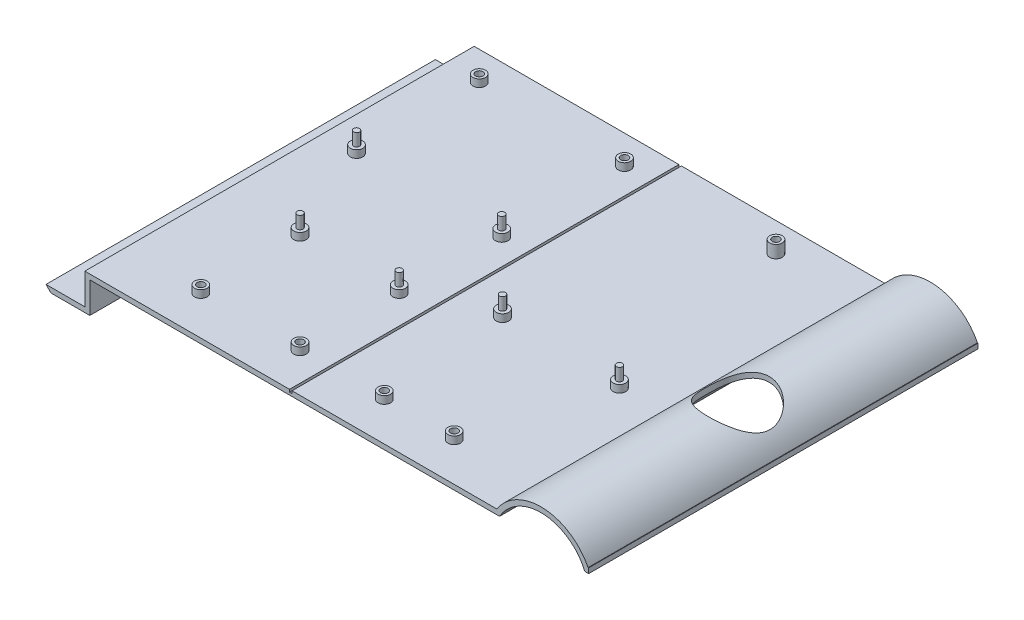
from build123d import *

# Parameters (mm, degrees)
LINEAR_AUSTRAGEN_D_NN1_DEPTH     = 155.5
SKIZZE7_R                        = 2.5
AUFSATZ_LINEAR_AUSTRAGEN3_DEPTH  = 5
SKIZZE8_R                        = 1.5
SCHNITT_LINEAR_AUSTRAGEN1_DEPTH  = 8
SKIZZE12_R                       = 1.5
SCHNITT_LINEAR_AUSTRAGEN4_DEPTH  = 8
SKIZZE13_R                       = 2.5
AUFSATZ_LINEAR_AUSTRAGEN5_DEPTH  = 5
SKIZZE16_R                       = 1.5
SCHNITT_LINEAR_AUSTRAGEN9_DEPTH  = 8
SKIZZE17_R                       = 1.5
SCHNITT_LINEAR_AUSTRAGEN10_DEPTH = 8
SKIZZE18_R                       = 2.5
AUFSATZ_LINEAR_AUSTRAGEN6_DEPTH  = 5
SKIZZE21_R                       = 1.5
SCHNITT_LINEAR_AUSTRAGEN13_DEPTH = 8
SKIZZE22_R                       = 1.5
SCHNITT_LINEAR_AUSTRAGEN14_DEPTH = 8
SKIZZE20_R                       = 1.2
AUFSATZ_LINEAR_AUSTRAGEN7_DEPTH  = 5
SKIZZE19_R                       = 1.2
AUFSATZ_LINEAR_AUSTRAGEN8_DEPTH  = 5
SKIZZE15_R                       = 1.2
AUFSATZ_LINEAR_AUSTRAGEN9_DEPTH  = 5
SKIZZE14_R                       = 1.2
AUFSATZ_LINEAR_AUSTRAGEN11_DEPTH = 5
SKIZZE10_R                       = 1.2
AUFSATZ_LINEAR_AUSTRAGEN12_DEPTH = 5
SKIZZE11_R                       = 1.2
AUFSATZ_LINEAR_AUSTRAGEN13_DEPTH = 5
CUT_EXTRUDE2_DEPTH               = 156.5
SKIZZE23_R                       = 13
SCHNITT_LINEAR_AUSTRAGEN15_DEPTH = 13
SKETCH5_W                        = 1
SKETCH5_H                        = 155.5
CUT_EXTRUDE_THIN1_DEPTH          = 1
SKETCH6_R                        = 2.5
SKETCH6_R_2                      = 1.5
BOSS_EXTRUDE1_DEPTH              = 5
CUT_EXTRUDE3_START               = -2
SKETCH7_R                        = 1.5
CUT_EXTRUDE3_DEPTH               = 2


with BuildPart() as part:
    # Skizze5 → Linear-Austragen-Dünn1 (new body)
    with BuildSketch(Plane.XY):
        with BuildLine():
            Line((-17.5, -12.340428851), (0, -12.340428851))
            Line((0, -12.340428851), (0, 0))
            Line((0, 0), (158.213118455, 0))
            Line((158.213118455, 0), (163.626964647, 0))
            ThreePointArc((163.626964647, 0), (171.029319744, 7.247508118), (181.129906705, 9.549545901))
            ThreePointArc((181.129906705, 9.549545901), (191.077251396, 6.131307404), (197.694328428, -2.044774322))
            Line((197.694328428, -2.044774322), (199.194328428, -2.044774322))
            Line((199.194328428, -2.044774322), (199.194328428, -0.044774322))
            Line((199.194328428, -0.044774322), (198.972575208, -0.044774322))
            ThreePointArc((198.972575208, -0.044774322), (191.667573532, 8.146277022), (181.232439294, 11.546915938))
            ThreePointArc((181.232439294, 11.546915938), (170.592452046, 9.278075868), (162.50625544, 2))
            Line((162.50625544, 2), (158.213118455, 2))
            Line((158.213118455, 2), (-2, 2))
            Line((-2, 2), (-2, -10.340428851))
            Line((-2, -10.340428851), (-17.5, -10.340428851))
            Line((-17.5, -10.340428851), (-17.5, -12.340428851))
        make_face()
    extrude(amount=LINEAR_AUSTRAGEN_D_NN1_DEPTH)

    # Skizze7 → Aufsatz-Linear austragen3 (add)
    with BuildSketch(Plane(origin=(0.013003032, 0, 0), x_dir=(1, 0, 0), z_dir=(0, 1, 0))):
        with Locations((11.5, -11.5)):
            Circle(SKIZZE7_R)
        with Locations((69.5, -11.5)):
            Circle(SKIZZE7_R)
        with Locations((11.5, -60.5)):
            Circle(SKIZZE7_R)
        with Locations((69.5, -60.5)):
            Circle(SKIZZE7_R)
    extrude(amount=AUFSATZ_LINEAR_AUSTRAGEN3_DEPTH)

    # Skizze8 → Schnitt-Linear austragen1 (cut)
    with BuildSketch(Plane(origin=(0, 5, 0), x_dir=(1, 0, 0), z_dir=(0, 1, 0))):
        with Locations((11.513003032, -11.5)):
            Circle(SKIZZE8_R)
    extrude(amount=-SCHNITT_LINEAR_AUSTRAGEN1_DEPTH, mode=Mode.SUBTRACT)

    # Skizze12 → Schnitt-Linear austragen4 (cut)
    with BuildSketch(Plane(origin=(0, 5, 0), x_dir=(1, 0, 0), z_dir=(0, 1, 0))):
        with Locations((69.513003032, -11.5)):
            Circle(SKIZZE12_R)
    extrude(amount=-SCHNITT_LINEAR_AUSTRAGEN4_DEPTH, mode=Mode.SUBTRACT)

    # Skizze13 → Aufsatz-Linear austragen5 (add)
    with BuildSketch(Plane(origin=(0.013003032, 0, 0), x_dir=(1, 0, 0), z_dir=(0, 1, 0))):
        with Locations((130, -140)):
            Circle(SKIZZE13_R)
        with Locations((102.1, -140)):
            Circle(SKIZZE13_R)
        with Locations((145.2, -89.2)):
            Circle(SKIZZE13_R)
        with Locations((97.4, -88.1)):
            Circle(SKIZZE13_R)
    extrude(amount=AUFSATZ_LINEAR_AUSTRAGEN5_DEPTH)

    # Skizze16 → Schnitt-Linear austragen9 (cut)
    with BuildSketch(Plane(origin=(0, 5, 0), x_dir=(1, 0, 0), z_dir=(0, 1, 0))):
        with Locations((102.113003032, -140)):
            Circle(SKIZZE16_R)
    extrude(amount=-SCHNITT_LINEAR_AUSTRAGEN9_DEPTH, mode=Mode.SUBTRACT)

    # Skizze17 → Schnitt-Linear austragen10 (cut)
    with BuildSketch(Plane(origin=(0, 5, 0), x_dir=(1, 0, 0), z_dir=(0, 1, 0))):
        with Locations((130.013003032, -140)):
            Circle(SKIZZE17_R)
    extrude(amount=-SCHNITT_LINEAR_AUSTRAGEN10_DEPTH, mode=Mode.SUBTRACT)

    # Skizze18 → Aufsatz-Linear austragen6 (add)
    with BuildSketch(Plane(origin=(0.013003032, 0, 0), x_dir=(1, 0, 0), z_dir=(0, 1, 0))):
        with Locations((68.430981836, -140)):
            Circle(SKIZZE18_R)
        with Locations((28.830981836, -140)):
            Circle(SKIZZE18_R)
        with Locations((28.83098184, -100.4)):
            Circle(SKIZZE18_R)
        with Locations((68.430981836, -100.4)):
            Circle(SKIZZE18_R)
    extrude(amount=AUFSATZ_LINEAR_AUSTRAGEN6_DEPTH)

    # Skizze21 → Schnitt-Linear austragen13 (cut)
    with BuildSketch(Plane(origin=(0, 5, 0), x_dir=(1, 0, 0), z_dir=(0, 1, 0))):
        with Locations((28.843984868, -140)):
            Circle(SKIZZE21_R)
    extrude(amount=-SCHNITT_LINEAR_AUSTRAGEN13_DEPTH, mode=Mode.SUBTRACT)

    # Skizze22 → Schnitt-Linear austragen14 (cut)
    with BuildSketch(Plane(origin=(0, 5, 0), x_dir=(1, 0, 0), z_dir=(0, 1, 0))):
        with Locations((68.443984868, -140)):
            Circle(SKIZZE22_R)
    extrude(amount=-SCHNITT_LINEAR_AUSTRAGEN14_DEPTH, mode=Mode.SUBTRACT)

    # Skizze20 → Aufsatz-Linear austragen7 (add)
    with BuildSketch(Plane(origin=(0, 5, 0), x_dir=(1, 0, 0), z_dir=(0, 1, 0))):
        with Locations((28.843984872, -100.4)):
            Circle(SKIZZE20_R)
    extrude(amount=AUFSATZ_LINEAR_AUSTRAGEN7_DEPTH)

    # Skizze19 → Aufsatz-Linear austragen8 (add)
    with BuildSketch(Plane(origin=(0, 5, 0), x_dir=(1, 0, 0), z_dir=(0, 1, 0))):
        with Locations((68.443984868, -100.4)):
            Circle(SKIZZE19_R)
    extrude(amount=AUFSATZ_LINEAR_AUSTRAGEN8_DEPTH)

    # Skizze15 → Aufsatz-Linear austragen9 (add)
    with BuildSketch(Plane(origin=(0, 5, 0), x_dir=(1, 0, 0), z_dir=(0, 1, 0))):
        with Locations((97.413003032, -88.1)):
            Circle(SKIZZE15_R)
    extrude(amount=AUFSATZ_LINEAR_AUSTRAGEN9_DEPTH)

    # Skizze14 → Aufsatz-Linear austragen11 (add)
    with BuildSketch(Plane(origin=(0, 5, 0), x_dir=(1, 0, 0), z_dir=(0, 1, 0))):
        with Locations((145.213003032, -89.2)):
            Circle(SKIZZE14_R)
    extrude(amount=AUFSATZ_LINEAR_AUSTRAGEN11_DEPTH)

    # Skizze10 → Aufsatz-Linear austragen12 (add)
    with BuildSketch(Plane(origin=(0, 5, 0), x_dir=(1, 0, 0), z_dir=(0, 1, 0))):
        with Locations((11.513003032, -60.5)):
            Circle(SKIZZE10_R)
    extrude(amount=AUFSATZ_LINEAR_AUSTRAGEN12_DEPTH)

    # Skizze11 → Aufsatz-Linear austragen13 (add)
    with BuildSketch(Plane(origin=(0, 5, 0), x_dir=(1, 0, 0), z_dir=(0, 1, 0))):
        with Locations((69.513003032, -60.5)):
            Circle(SKIZZE11_R)
    extrude(amount=AUFSATZ_LINEAR_AUSTRAGEN13_DEPTH)

    # Sketch3 → Cut-Extrude2 (cut, through all)
    with BuildSketch(Plane(origin=(0, 0, 0), x_dir=(-1, 0, 0), z_dir=(0, 0, -1))):
        Polygon((17.5, -10.340428851), (15.5, -12.340428851), (17.5, -12.340428851), align=None)
    extrude(amount=-CUT_EXTRUDE2_DEPTH, mode=Mode.SUBTRACT)

    # Skizze23 → Schnitt-Linear austragen15 (cut)
    with BuildSketch(Plane(origin=(0, 2, 0), x_dir=(1, 0, 0), z_dir=(0, 1, 0))):
        with Locations((181, -77.85)):
            Circle(SKIZZE23_R)
    extrude(amount=SCHNITT_LINEAR_AUSTRAGEN15_DEPTH, mode=Mode.SUBTRACT)

    # Sketch5 → Cut-Extrude-Thin1 (cut)
    with BuildSketch(Plane(origin=(0, 2, 0), x_dir=(1, 0, 0), z_dir=(0, 1, 0))):
        with Locations((80.25312772, -77.75)):
            Rectangle(SKETCH5_W, SKETCH5_H)
    extrude(amount=-CUT_EXTRUDE_THIN1_DEPTH, mode=Mode.SUBTRACT)

    # Sketch6 → Boss-Extrude1 (add)
    with BuildSketch(Plane(origin=(0, 2, 0), x_dir=(1, 0, 0), z_dir=(0, 1, 0))):
        with Locations((130.01300303, -11.5)):
            Circle(SKETCH6_R)
        with Locations((130.01300303, -11.5)):
            Circle(SKETCH6_R_2, mode=Mode.SUBTRACT)
    extrude(amount=BOSS_EXTRUDE1_DEPTH)

    # Sketch7 → Cut-Extrude3 (cut)
    with BuildSketch(Plane(origin=(0, 2, 0), x_dir=(1, 0, 0), z_dir=(0, 1, 0)).offset(CUT_EXTRUDE3_START)):
        with Locations((130.01300303, -11.5)):
            Circle(SKETCH7_R)
    extrude(amount=CUT_EXTRUDE3_DEPTH, mode=Mode.SUBTRACT)


solid = part.part
